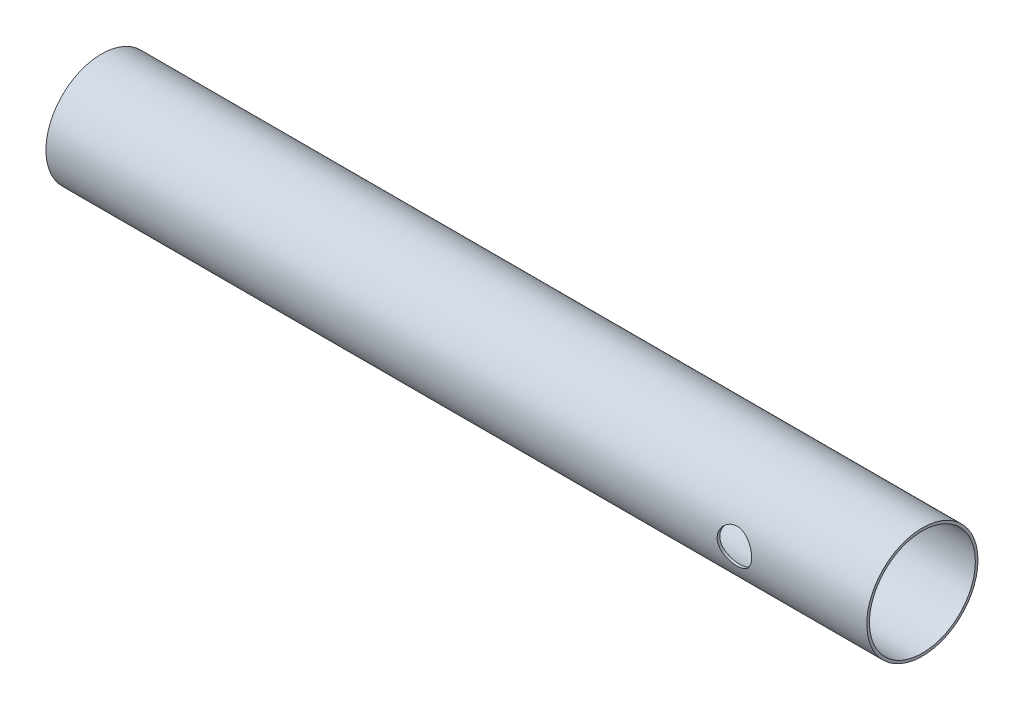
from build123d import *

# Parameters (mm, degrees)
CROQUIS1_R              = 10.5
SALIENTE_EXTRUIR1_DEPTH = 155
CROQUIS2_R              = 10
CORTAR_EXTRUIR1_DEPTH   = 155
CROQUIS3_R              = 3.25
CORTAR_EXTRUIR2_DEPTH   = 2.5


with BuildPart() as part:
    # Croquis1 → Saliente-Extruir1 (new body)
    with BuildSketch(Plane(origin=(0, 0, 0), x_dir=(0, 0, -1), z_dir=(1, 0, 0))):
        Circle(CROQUIS1_R)
    extrude(amount=SALIENTE_EXTRUIR1_DEPTH)

    # Croquis2 → Cortar-Extruir1 (cut)
    with BuildSketch(Plane(origin=(155, 0, 0), x_dir=(0, 0, -1), z_dir=(1, 0, 0))):
        Circle(CROQUIS2_R)
    extrude(amount=-CORTAR_EXTRUIR1_DEPTH, mode=Mode.SUBTRACT)

    # Croquis3 → Cortar-Extruir2 (cut, symmetric)
    with BuildSketch(Plane.XY.offset(10.369970807)):
        with Locations((130, 0)):
            Circle(CROQUIS3_R)
    extrude(amount=CORTAR_EXTRUIR2_DEPTH, both=True, mode=Mode.SUBTRACT)


solid = part.part
